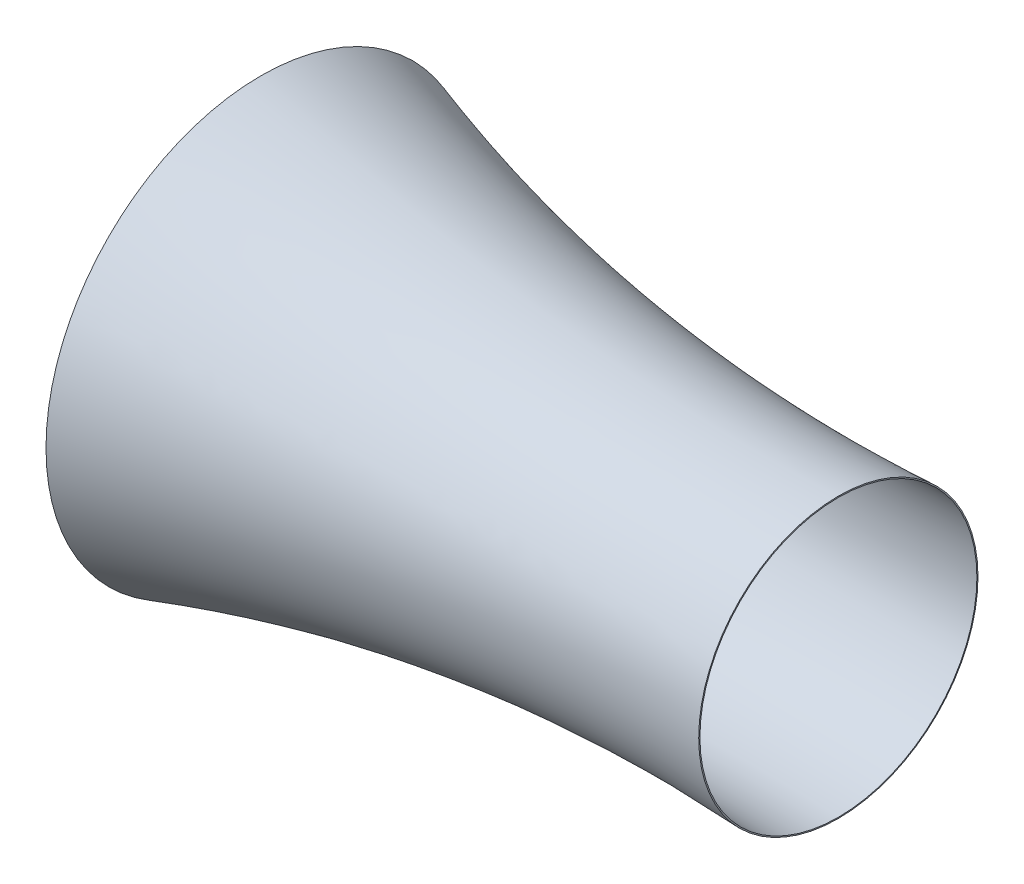
from build123d import *

# Parameters (mm, degrees)
THICKEN1_T1 = 5


with BuildPart() as body_1:
    # Surface-Revolve1: a surface, the sketch's curves turned about an axis
    with BuildLine(Plane.XY, mode=Mode.PRIVATE) as surface_revolve1_1_path:
        Line((58.164522356, 830), (33.164522356, 830))
        Line((33.164522356, 830), (25, 800))
        Line((25, 800), (0, 800))
        add(Edge.make_bspline(
            [(0, 800), (-40.64487716, 858.757553751), (0, 924.826053007)],
            knots=[0, 0, 0, 1, 1, 1], degree=2))
        add(Edge.make_bspline(
            [(0, 924.826053007), (1213.175487554, 535.365100613), (2500, 600)],
            knots=[0, 0, 0, 1, 1, 1], degree=2))
    surface_revolve1_1 = Shell.revolve(surface_revolve1_1_path.wire(), 360, Axis((0, 0, 0), (1, 0, 0)))
    add(Solid.thicken(surface_revolve1_1, THICKEN1_T1))


solid = body_1.part
